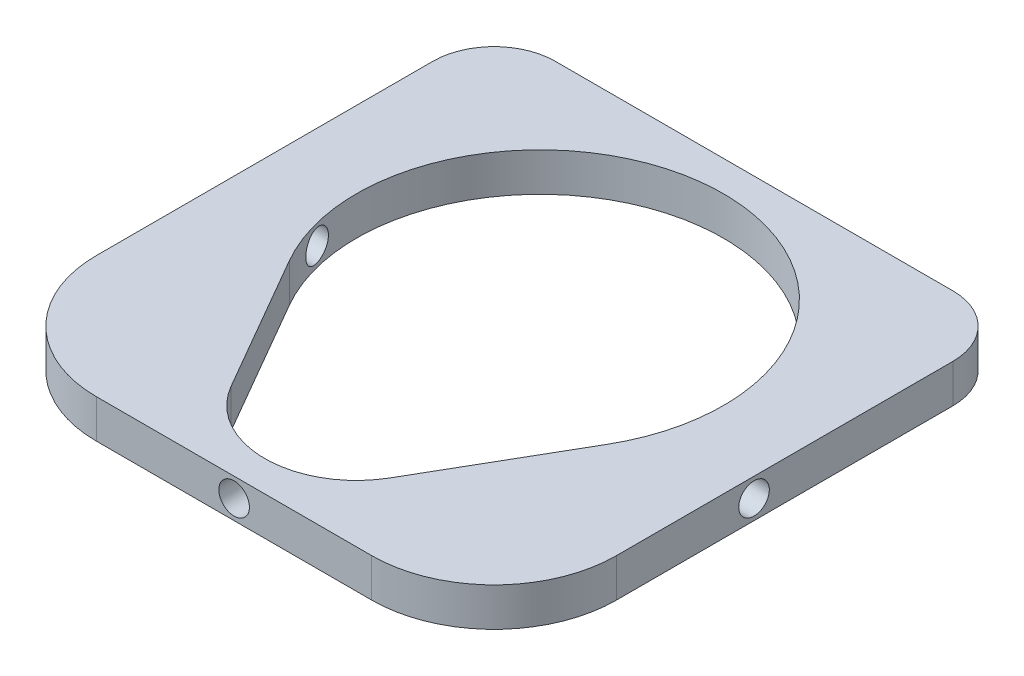
from build123d import *

# Parameters (mm, degrees)
SKETCH1_W           = 85
SKETCH1_H           = 85
BOSS_EXTRUDE1_DEPTH = 6.3
CUT_EXTRUDE1_DEPTH  = 10
CUT_EXTRUDE2_REACH  = 87
SKETCH3_R           = 2.5
SKETCH4_R           = 2.5
CUT_EXTRUDE3_DEPTH  = 86
FILLET1_R           = 20
FILLET2_R           = 10


with BuildPart() as part:
    # Sketch1 → Boss-Extrude1 (new body)
    with BuildSketch(Plane(origin=(0, 0, 0), x_dir=(1, 0, 0), z_dir=(0, 1, 0))):
        with Locations((42.5, 42.5)):
            Rectangle(SKETCH1_W, SKETCH1_H)
    extrude(amount=BOSS_EXTRUDE1_DEPTH)

    # Sketch2 → Cut-Extrude1 (cut)
    with BuildSketch(Plane(origin=(0, 6.3, 0), x_dir=(1, 0, 0), z_dir=(0, 1, 0))):
        with BuildLine():
            Line((16.519237886, 35), (29.509618943, 12.5))
            ThreePointArc((29.509618943, 12.5), (42.5, 5), (55.490381057, 12.5))
            Line((55.490381057, 12.5), (68.480762114, 35))
            ThreePointArc((68.480762114, 35), (42.5, 80), (16.519237886, 35))
        make_face()
    extrude(amount=-CUT_EXTRUDE1_DEPTH, mode=Mode.SUBTRACT)

    # Sketch3 → Cut-Extrude2 (cut, up to next)
    with BuildSketch(Plane.XY, mode=Mode.PRIVATE) as cut_extrude2_sk1:
        with Locations((42.5, 3.15)):
            Circle(SKETCH3_R)
    cut_extrude2_tool1 = extrude(cut_extrude2_sk1.sketch, amount=-CUT_EXTRUDE2_REACH, mode=Mode.PRIVATE) & part.part
    add(cut_extrude2_tool1.solids().sort_by_distance((42.5, 3.15, 0))[0], mode=Mode.SUBTRACT)

    # Sketch4 → Cut-Extrude3 (cut, through all)
    with BuildSketch(Plane.ZY):
        with Locations((-42.5, 3.15)):
            Circle(SKETCH4_R)
    extrude(amount=-CUT_EXTRUDE3_DEPTH, mode=Mode.SUBTRACT)

    # Fillet1
    fillet1_edges = [part.edges().sort_by_distance(p)[0] for p in [
        (85, 3.15, 0),
        (0, 3.15, 0),
    ]]
    fillet(fillet1_edges, radius=FILLET1_R)

    # Fillet2
    fillet2_edges = [part.edges().sort_by_distance(p)[0] for p in [
        (0, 3.15, -85),
        (85, 3.15, -85),
    ]]
    fillet(fillet2_edges, radius=FILLET2_R)


solid = part.part
